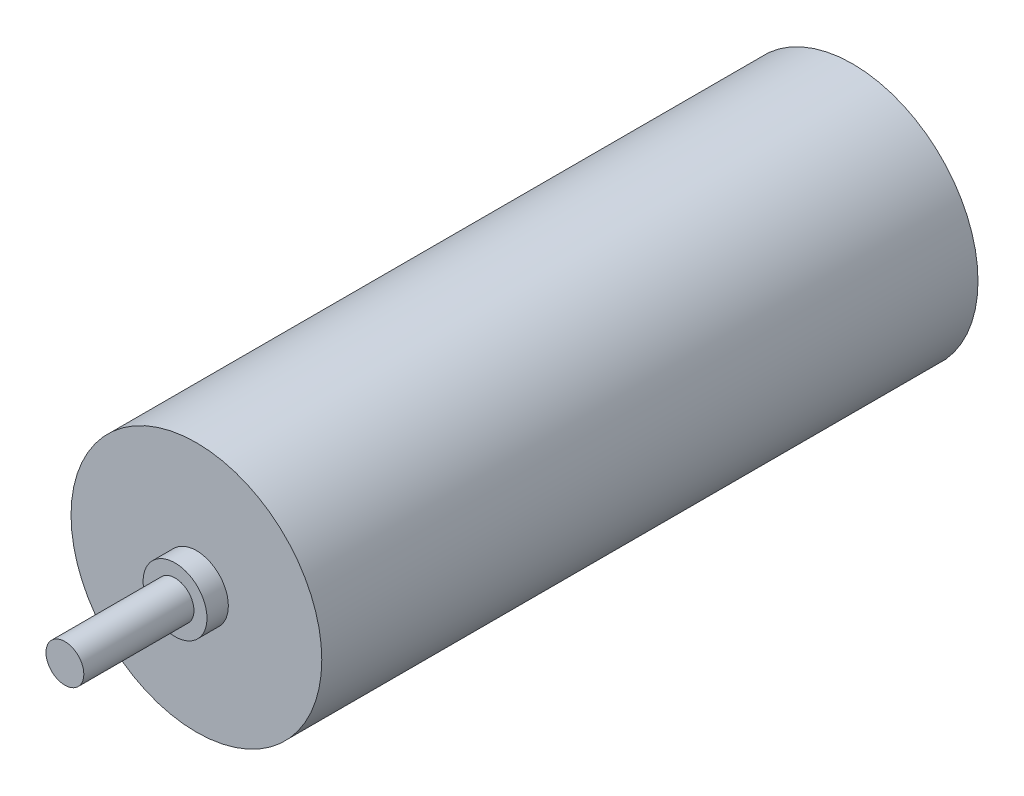
from build123d import *

# Parameters (mm, degrees)
SKETCH1_R           = 13.25
BOSS_EXTRUDE1_DEPTH = 69.35
SKETCH2_R           = 3.375
BOSS_EXTRUDE2_DEPTH = 2.26
SKETCH3_R           = 2
BOSS_EXTRUDE3_DEPTH = 11.64


with BuildPart() as part:
    # Sketch1 → Boss-Extrude1 (new body)
    with BuildSketch(Plane.XY):
        Circle(SKETCH1_R)
    extrude(amount=BOSS_EXTRUDE1_DEPTH)

    # Sketch2 → Boss-Extrude2 (add)
    with BuildSketch(Plane.XY.offset(69.35)):
        Circle(SKETCH2_R)
    extrude(amount=BOSS_EXTRUDE2_DEPTH)

    # Sketch3 → Boss-Extrude3 (add)
    with BuildSketch(Plane.XY.offset(71.61)):
        Circle(SKETCH3_R)
    extrude(amount=BOSS_EXTRUDE3_DEPTH)


solid = part.part
